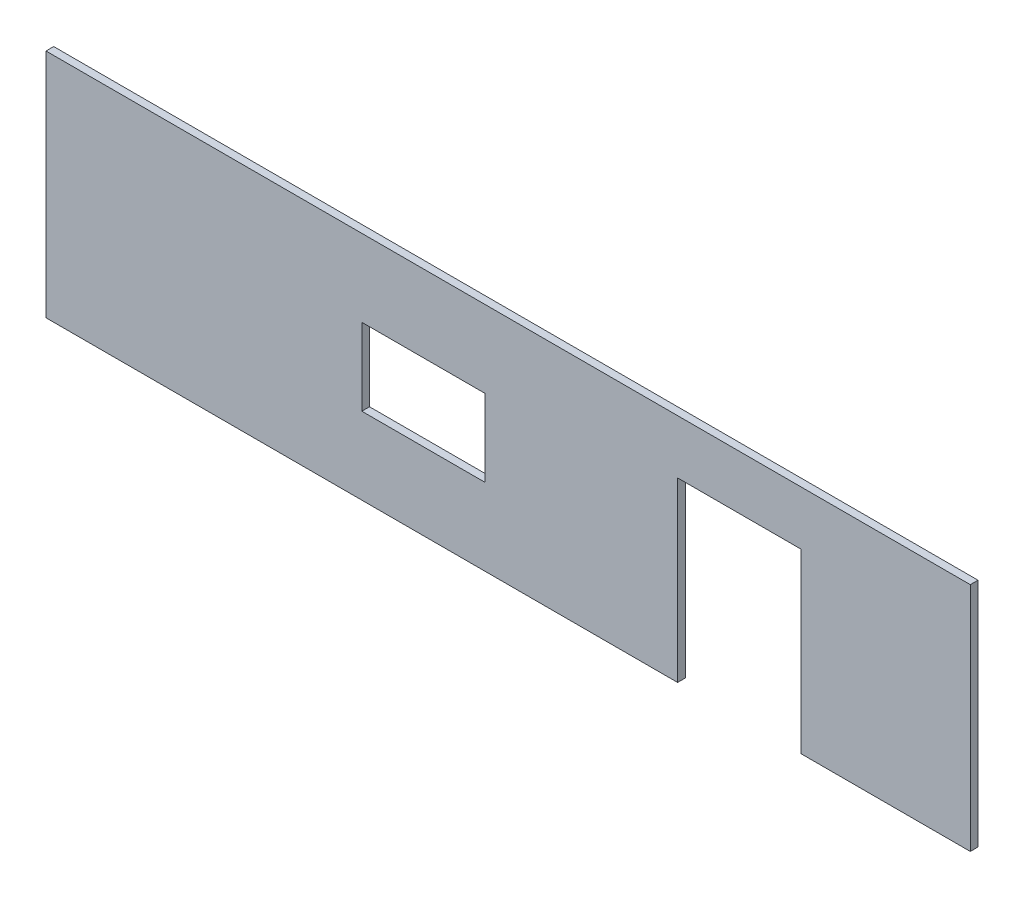
from build123d import *

# Parameters (mm, degrees)
SKETCH1_W           = 80
SKETCH1_H           = 50
BOSS_EXTRUDE1_DEPTH = 5


with BuildPart() as part:
    # Sketch1 → Boss-Extrude1 (new body)
    with BuildSketch(Plane.XY):
        Polygon((-300, 75), (300, 75), (300, -75), (190, -75), (190, 40), (110, 40), (110, -75), (-300, -75), align=None)
        with Locations((-55, 0)):
            Rectangle(SKETCH1_W, SKETCH1_H, mode=Mode.SUBTRACT)
    extrude(amount=BOSS_EXTRUDE1_DEPTH)


solid = part.part
